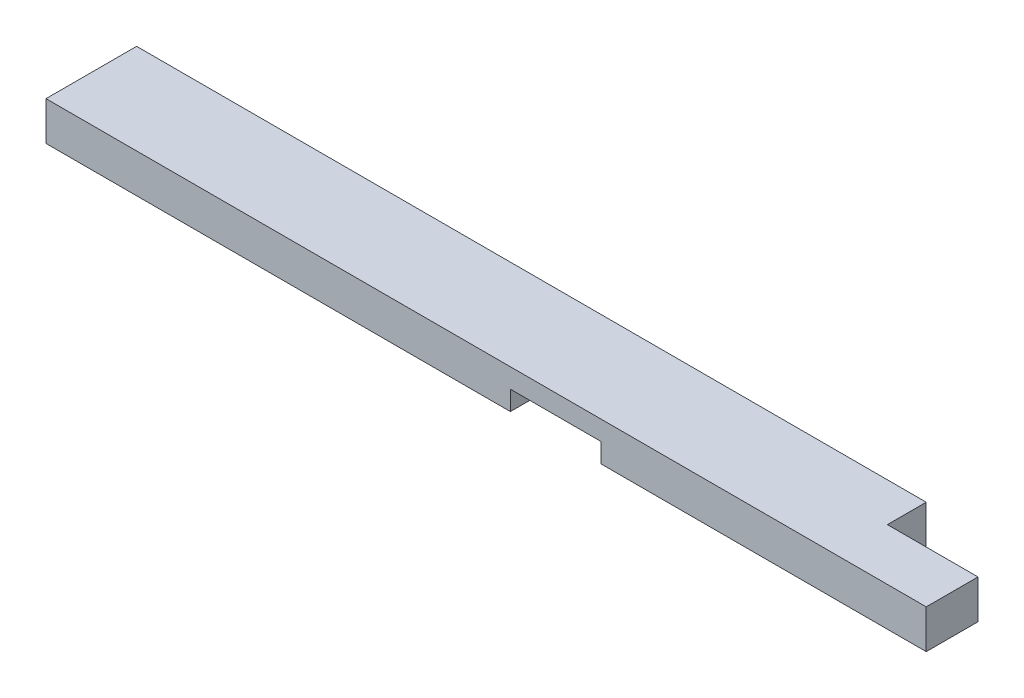
from build123d import *

# Parameters (mm, degrees)
SKETCH1_W           = 863.6
SKETCH1_H           = 88.9
BOSS_EXTRUDE1_DEPTH = 38.1
SKETCH3_W           = 88.9
SKETCH3_H           = 38.1
CUT_EXTRUDE2_DEPTH  = 39.1
SKETCH4_W           = 88.9
SKETCH4_H           = 19.05
CUT_EXTRUDE3_DEPTH  = 89.9


with BuildPart() as part:
    # Sketch1 → Boss-Extrude1 (new body)
    with BuildSketch(Plane(origin=(0, 0, 0), x_dir=(1, 0, 0), z_dir=(0, 1, 0))):
        with Locations((431.8, 44.45)):
            Rectangle(SKETCH1_W, SKETCH1_H)
    extrude(amount=BOSS_EXTRUDE1_DEPTH)

    # Sketch3 → Cut-Extrude2 (cut, through all)
    with BuildSketch(Plane(origin=(0, 38.1, 0), x_dir=(1, 0, 0), z_dir=(0, 1, 0))):
        with Locations((819.15, 69.85)):
            Rectangle(SKETCH3_W, SKETCH3_H)
    extrude(amount=-CUT_EXTRUDE2_DEPTH, mode=Mode.SUBTRACT)

    # Sketch4 → Cut-Extrude3 (cut, through all)
    with BuildSketch(Plane(origin=(0, 0, -88.9), x_dir=(-1, 0, 0), z_dir=(0, 0, -1))):
        with Locations((-500.0625, 9.525)):
            Rectangle(SKETCH4_W, SKETCH4_H)
    extrude(amount=-CUT_EXTRUDE3_DEPTH, mode=Mode.SUBTRACT)


solid = part.part
